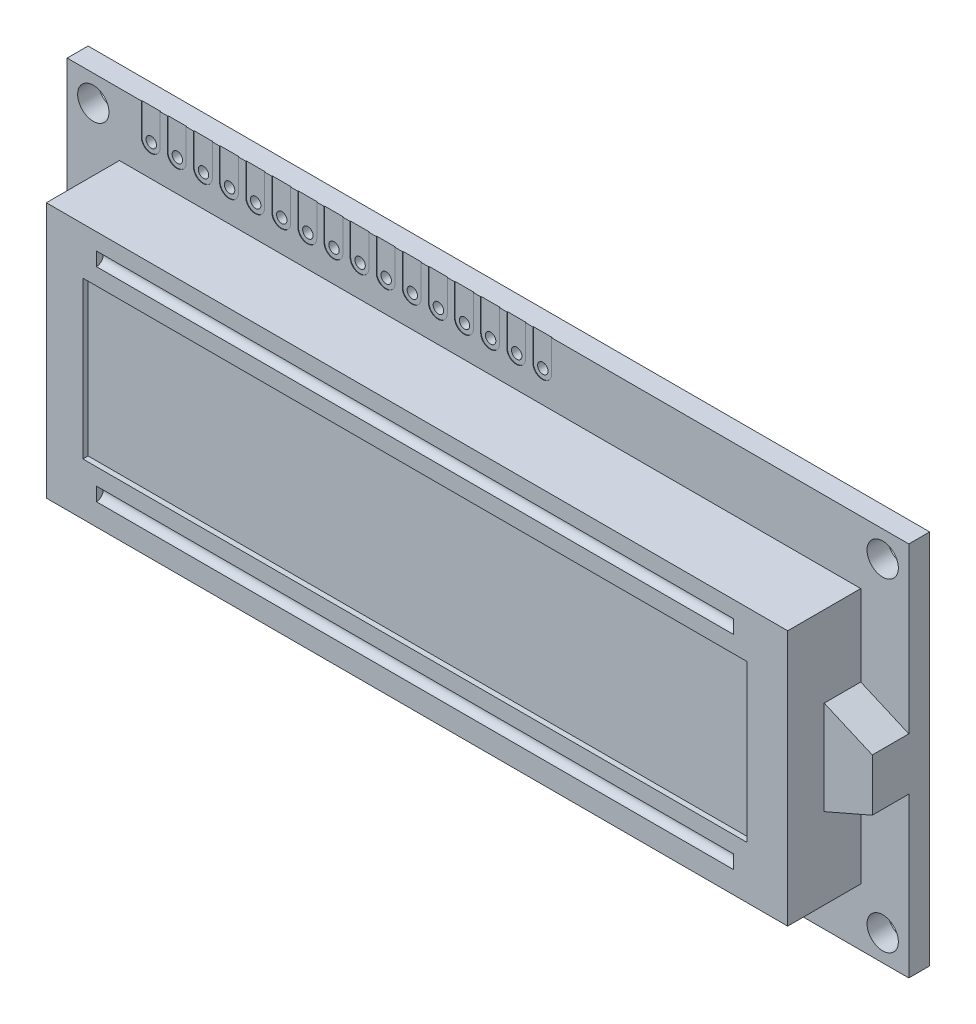
from build123d import *

# Parameters (mm, degrees)
CROQUIS1_W                 = 80.6
CROQUIS1_H                 = 36
CROQUIS1_R                 = 1.5
SALIENTE_EXTRUIR1_DEPTH    = 2
CROQUIS2_W                 = 71
CROQUIS2_H                 = 24.5
SALIENTE_EXTRUIR2_DEPTH    = 7
CROQUIS3_W                 = 63.6
CROQUIS3_H                 = 15
CORTAR_EXTRUIR1_DEPTH      = 0.5
CORTAR_EXTRUIR2_DEPTH      = 30.5
CORTAR_EXTRUIR2_DEPTH_BACK = 30.5
SALIENTE_EXTRUIR3_DEPTH    = 3.5
CROQUIS6_R                 = 0.5
CORTAR_EXTRUIR3_DEPTH      = 3.5
CROQUIS8_R                 = 0.5
CORTAR_EXTRUIR4_DEPTH      = 0.05
MATRIZL1_COUNT             = 16
MATRIZL1_PITCH             = 2.5


with BuildPart() as part:
    # Croquis1 → Saliente-Extruir1 (new body)
    with BuildSketch(Plane.XY):
        Rectangle(CROQUIS1_W, CROQUIS1_H)
        with Locations((37.8, 15.5)):
            Circle(CROQUIS1_R, mode=Mode.SUBTRACT)
        with Locations((-37.8, 15.5)):
            Circle(CROQUIS1_R, mode=Mode.SUBTRACT)
        with Locations((37.8, -15.5)):
            Circle(CROQUIS1_R, mode=Mode.SUBTRACT)
        with Locations((-37.8, -15.5)):
            Circle(CROQUIS1_R, mode=Mode.SUBTRACT)
    extrude(amount=SALIENTE_EXTRUIR1_DEPTH)

    # Croquis2 → Saliente-Extruir2 (add)
    with BuildSketch(Plane.XY.offset(2)):
        with Locations((0.2, -0.25)):
            Rectangle(CROQUIS2_W, CROQUIS2_H)
    extrude(amount=SALIENTE_EXTRUIR2_DEPTH)

    # Croquis3 → Cortar-Extruir1 (cut)
    with BuildSketch(Plane.XY.offset(9)):
        Rectangle(CROQUIS3_W, CROQUIS3_H)
    extrude(amount=-CORTAR_EXTRUIR1_DEPTH, mode=Mode.SUBTRACT)

    # Croquis4 → Cortar-Extruir2 (cut, two sides)
    with BuildSketch(Plane(origin=(0, 0, 0), x_dir=(0, 0, -1), z_dir=(1, 0, 0))) as cortar_extruir2_sk:
        with BuildLine():
            Line((-9, 10.401372799), (-9, 9.098123873))
            ThreePointArc((-9, 9.098123873), (-8.348627201, 9.75), (-9, 10.401372799))
        make_face()
        with BuildLine():
            ThreePointArc((-9, -9.098627201), (-8.348627201, -9.75), (-9, -10.401372799))
            Line((-9, -10.401372799), (-9, -9.098627201))
        make_face()
    extrude(amount=CORTAR_EXTRUIR2_DEPTH, mode=Mode.SUBTRACT)
    extrude(cortar_extruir2_sk.sketch, amount=-CORTAR_EXTRUIR2_DEPTH_BACK, mode=Mode.SUBTRACT)

    # Croquis5 → Saliente-Extruir3 (add)
    with BuildSketch(Plane.XY.offset(2)):
        Polygon((35.7, 4.25), (40.3, 2.25), (40.3, -2.75), (35.7, -4.75), align=None)
    extrude(amount=SALIENTE_EXTRUIR3_DEPTH)

    # Croquis6 → Cortar-Extruir3 (cut)
    with BuildSketch(Plane.XY.offset(2)):
        with Locations((-32.3, 15)):
            Circle(CROQUIS6_R)
        with Locations((-29.8, 15)):
            Circle(CROQUIS6_R)
        with Locations((-27.3, 15)):
            Circle(CROQUIS6_R)
        with Locations((-24.8, 15)):
            Circle(CROQUIS6_R)
        with Locations((-22.3, 15)):
            Circle(CROQUIS6_R)
        with Locations((-19.8, 15)):
            Circle(CROQUIS6_R)
        with Locations((-17.3, 15)):
            Circle(CROQUIS6_R)
        with Locations((-14.8, 15)):
            Circle(CROQUIS6_R)
        with Locations((-12.3, 15)):
            Circle(CROQUIS6_R)
        with Locations((-9.8, 15)):
            Circle(CROQUIS6_R)
        with Locations((-7.3, 15)):
            Circle(CROQUIS6_R)
        with Locations((-4.8, 15)):
            Circle(CROQUIS6_R)
        with Locations((-2.3, 15)):
            Circle(CROQUIS6_R)
        with Locations((0.2, 15)):
            Circle(CROQUIS6_R)
        with Locations((2.7, 15)):
            Circle(CROQUIS6_R)
        with Locations((5.2, 15)):
            Circle(CROQUIS6_R)
    extrude(amount=-CORTAR_EXTRUIR3_DEPTH, mode=Mode.SUBTRACT)

    # Croquis8 → Cortar-Extruir4 (cut)
    with BuildSketch(Plane.XY.offset(2)):
        with BuildLine():
            Line((-33.2, 15), (-33.2, 18))
            Line((-33.2, 18), (-31.4, 18))
            Line((-31.4, 18), (-31.4, 15))
            ThreePointArc((-31.4, 15), (-32.3, 14.1), (-33.2, 15))
        make_face()
        with Locations((-32.3, 15)):
            Circle(CROQUIS8_R, mode=Mode.SUBTRACT)
    cortar_extruir4 = extrude(amount=-CORTAR_EXTRUIR4_DEPTH, mode=Mode.SUBTRACT)

    # MatrizL1: Cortar-Extruir4 ×16
    with Locations(*[(i * MATRIZL1_PITCH, 0, 0) for i in range(1, MATRIZL1_COUNT)]):
        add(cortar_extruir4, mode=Mode.SUBTRACT)


solid = part.part
